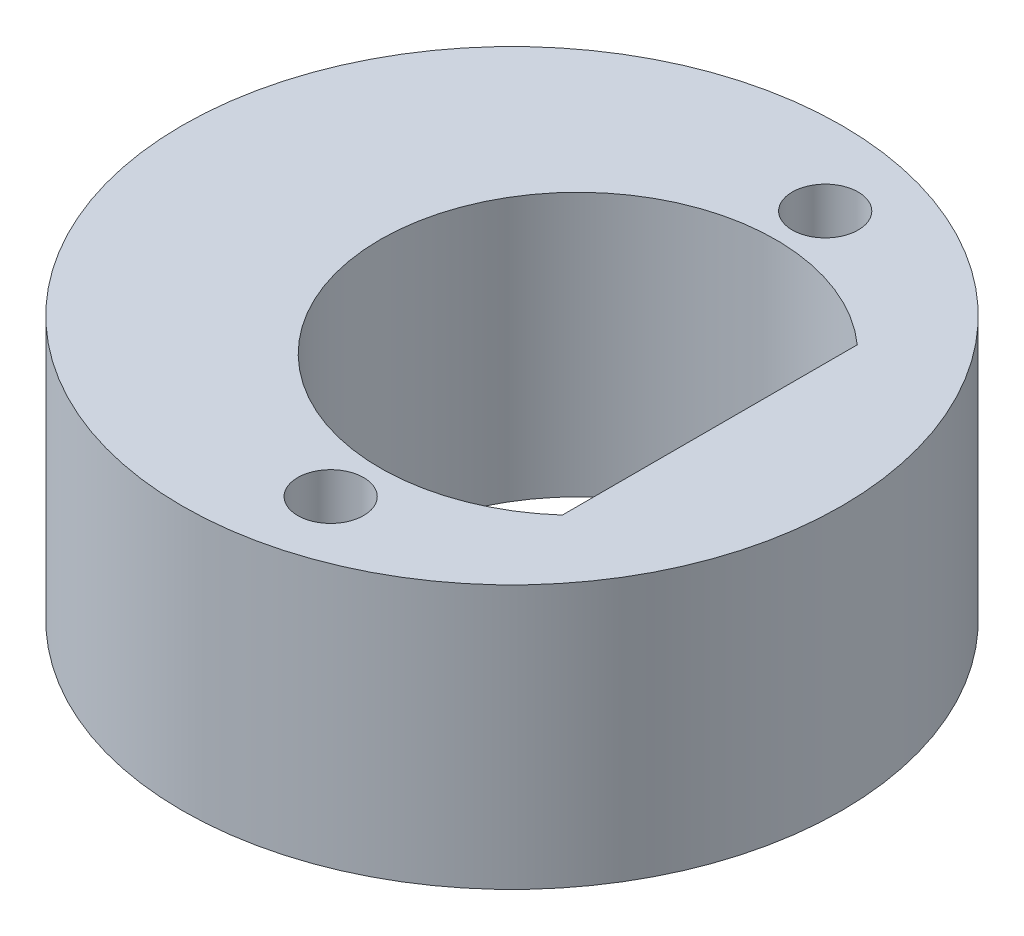
from build123d import *

# Parameters (mm, degrees)
SKETCH1_R           = 5
SKETCH1_R_2         = 3
BOSS_EXTRUDE1_DEPTH = 4
SKETCH2_R           = 0.5
CUT_EXTRUDE1_DEPTH  = 5
BOSS_EXTRUDE2_DEPTH = 4


with BuildPart() as part:
    # Sketch1 → Boss-Extrude1 (new body)
    with BuildSketch(Plane(origin=(0, 0, 0), x_dir=(1, 0, 0), z_dir=(0, 1, 0))):
        with Locations((-1, 0)):
            Circle(SKETCH1_R)
        Circle(SKETCH1_R_2, mode=Mode.SUBTRACT)
    extrude(amount=BOSS_EXTRUDE1_DEPTH)

    # Sketch2 → Cut-Extrude1 (cut, through all)
    with BuildSketch(Plane(origin=(0, 4, 0), x_dir=(1, 0, 0), z_dir=(0, 1, 0))):
        with Locations((0, 3.75)):
            Circle(SKETCH2_R)
        with Locations((0, -3.75)):
            Circle(SKETCH2_R)
    extrude(amount=-CUT_EXTRUDE1_DEPTH, mode=Mode.SUBTRACT)

    # Sketch3 → Boss-Extrude2 (add)
    with BuildSketch(Plane.XZ):
        with BuildLine():
            ThreePointArc((3, 0), (2.738612788, 1.224744871), (2, 2.236067977))
            Line((2, 2.236067977), (2, -2.236067977))
            ThreePointArc((2, -2.236067977), (2.738612788, -1.224744871), (3, 0))
        make_face()
    extrude(amount=-BOSS_EXTRUDE2_DEPTH)


solid = part.part
